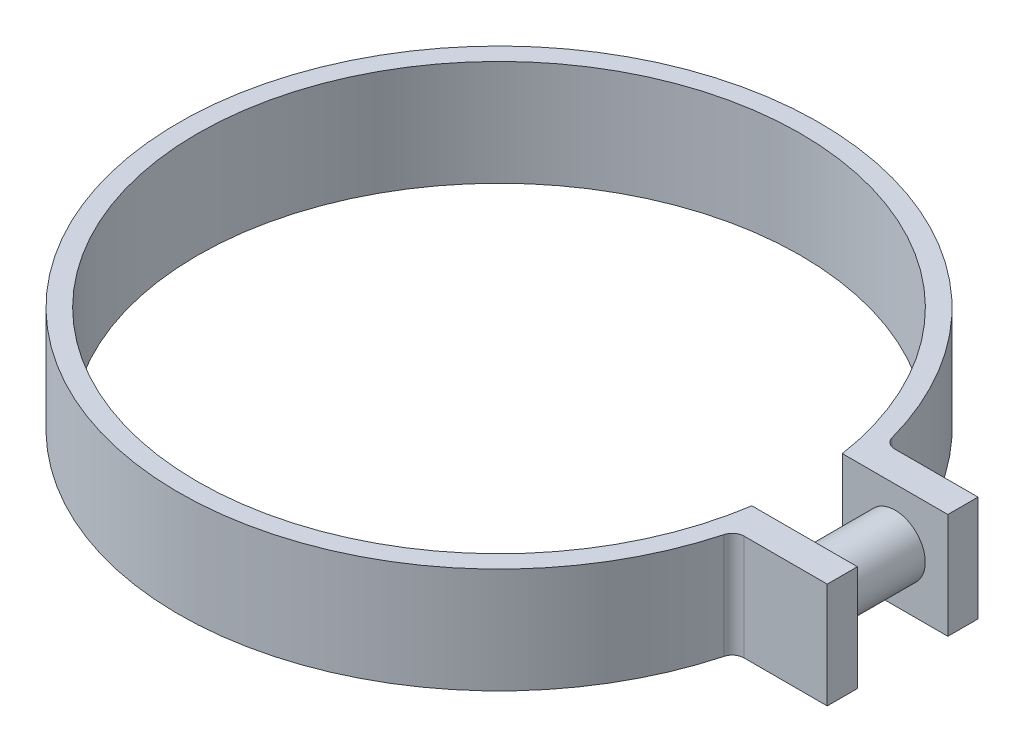
from build123d import *

# Parameters (mm, degrees)
BOSS_EXTRUDE1_DEPTH = 4.445
BOSS_EXTRUDE2_REACH = 32.797
SKETCH2_R           = 2.54


with BuildPart() as part:
    # Sketch1 → Boss-Extrude1 (new body, symmetric)
    with BuildSketch(Plane(origin=(0, 0, 0), x_dir=(1, 0, 0), z_dir=(0, 1, 0))):
        with BuildLine():
            Line((34.002624315, 3.81), (25.112624315, 3.81))
            ThreePointArc((25.112624315, 3.81), (-25.4, 0), (25.112624315, -3.81))
            Line((25.112624315, -3.81), (34.002624315, -3.81))
            Line((34.002624315, -3.81), (34.002624315, -6.35))
            Line((34.002624315, -6.35), (26.9875, -6.35))
            ThreePointArc((26.9875, -6.35), (26.394067972, -6.550896579), (26.04470524, -7.070960699))
            ThreePointArc((26.04470524, -7.070960699), (-26.9875, 0), (26.04470524, 7.070960699))
            ThreePointArc((26.04470524, 7.070960699), (26.394067972, 6.550896579), (26.9875, 6.35))
            Line((26.9875, 6.35), (34.002624315, 6.35))
            Line((34.002624315, 6.35), (34.002624315, 3.81))
        make_face()
    extrude(amount=BOSS_EXTRUDE1_DEPTH, both=True)

    # Sketch2 → Boss-Extrude2 (add, up to next)
    with BuildSketch(Plane.XY.offset(-3.81), mode=Mode.PRIVATE) as boss_extrude2_sk1:
        with Locations((29.557624315, 0)):
            Circle(SKETCH2_R)
    boss_extrude2_tool1 = extrude(boss_extrude2_sk1.sketch, amount=BOSS_EXTRUDE2_REACH, mode=Mode.PRIVATE) - part.part
    add(boss_extrude2_tool1.solids().sort_by_distance((29.557624, 0, -3.81))[0])


solid = part.part
